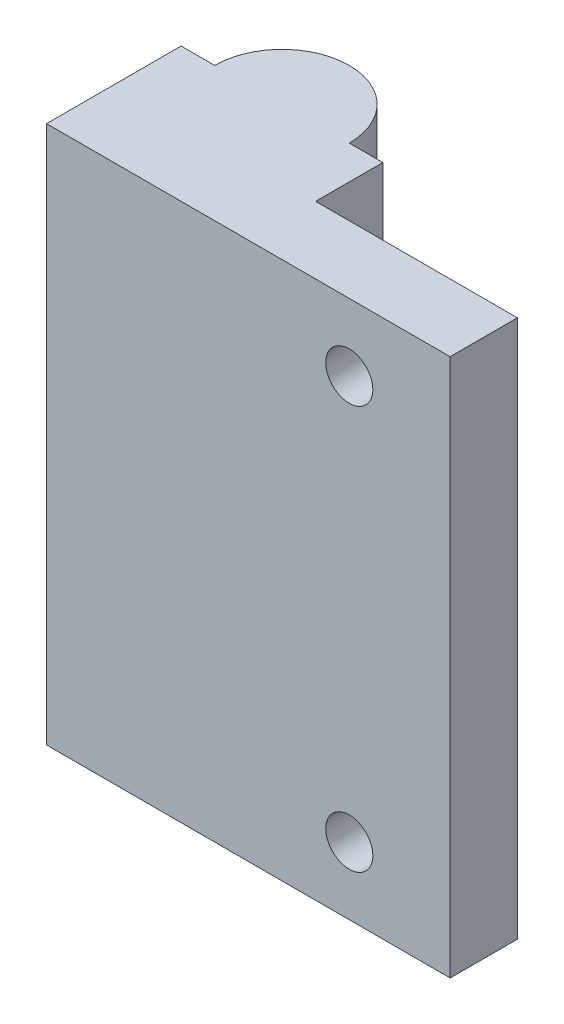
from build123d import *

# Parameters (mm, degrees)
SKETCH1_W           = 30
SKETCH1_H           = 40
BOSS_EXTRUDE1_DEPTH = 10
SKETCH2_W           = 15
SKETCH2_H           = 40
CUT_EXTRUDE1_DEPTH  = 5
SKETCH4_R           = 1.75
CUT_EXTRUDE3_DEPTH  = 30
SKETCH7_R           = 5
BOSS_EXTRUDE2_DEPTH = 40
SKETCH8_R           = 3.5
CUT_EXTRUDE4_DEPTH  = 30


with BuildPart() as part:
    # Sketch1 → Boss-Extrude1 (new body)
    with BuildSketch(Plane.XY):
        with Locations((15, 20)):
            Rectangle(SKETCH1_W, SKETCH1_H)
    extrude(amount=BOSS_EXTRUDE1_DEPTH)

    # Sketch2 → Cut-Extrude1 (cut)
    with BuildSketch(Plane(origin=(0, 0, 0), x_dir=(-1, 0, 0), z_dir=(0, 0, -1))):
        with Locations((-22.5, 20)):
            Rectangle(SKETCH2_W, SKETCH2_H)
    extrude(amount=-CUT_EXTRUDE1_DEPTH, mode=Mode.SUBTRACT)

    # Sketch4 → Cut-Extrude3 (cut)
    with BuildSketch(Plane(origin=(0, 0, 5), x_dir=(-1, 0, 0), z_dir=(0, 0, -1))):
        with Locations((-22.5, 5)):
            Circle(SKETCH4_R)
        with Locations((-22.5, 35)):
            Circle(SKETCH4_R)
    extrude(amount=-CUT_EXTRUDE3_DEPTH, mode=Mode.SUBTRACT)

    # Sketch7 → Boss-Extrude2 (add)
    with BuildSketch(Plane.XZ):
        with Locations((7.5, 0)):
            Circle(SKETCH7_R)
    extrude(amount=-BOSS_EXTRUDE2_DEPTH)

    # Sketch8 → Cut-Extrude4 (cut)
    with BuildSketch(Plane.XZ):
        with Locations((7.5, 0)):
            Circle(SKETCH8_R)
    extrude(amount=-CUT_EXTRUDE4_DEPTH, mode=Mode.SUBTRACT)


solid = part.part
